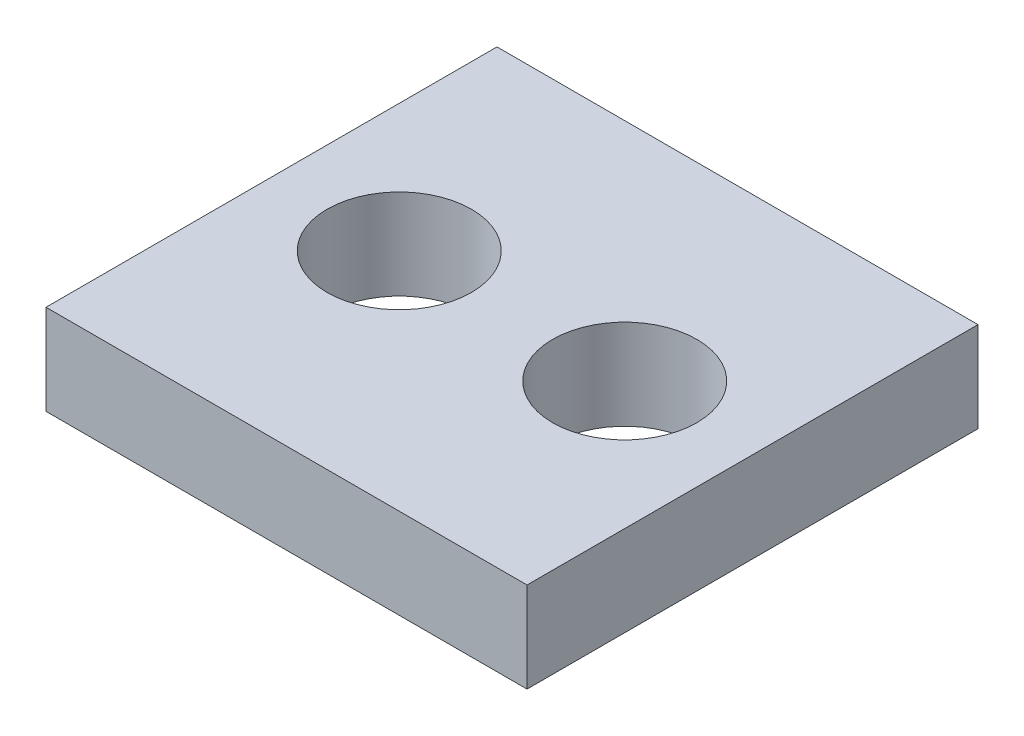
from build123d import *

# Parameters (mm, degrees)
SKETCH1_W           = 16
SKETCH1_H           = 15
BOSS_EXTRUDE1_DEPTH = 3
CUT_EXTRUDE1_START  = -4
SKETCH2_R           = 2.4
CUT_EXTRUDE1_DEPTH  = 5


with BuildPart() as part:
    # Sketch1 → Boss-Extrude1 (new body)
    with BuildSketch(Plane(origin=(0, 0, 0), x_dir=(1, 0, 0), z_dir=(0, 1, 0))):
        Rectangle(SKETCH1_W, SKETCH1_H)
    extrude(amount=BOSS_EXTRUDE1_DEPTH)

    # Sketch2 → Cut-Extrude1 (cut)
    with BuildSketch(Plane(origin=(0, 3, 0), x_dir=(1, 0, 0), z_dir=(0, 1, 0)).offset(CUT_EXTRUDE1_START)):
        with Locations((-3.75, 0)):
            Circle(SKETCH2_R)
    cut_extrude1 = extrude(amount=CUT_EXTRUDE1_DEPTH, mode=Mode.SUBTRACT)

    # Mirror1: Cut-Extrude1 across plane
    add(cut_extrude1.mirror(Plane(origin=(0, 0, 0), x_dir=(0, 0, 1), z_dir=(1, 0, 0))), mode=Mode.SUBTRACT)


solid = part.part
